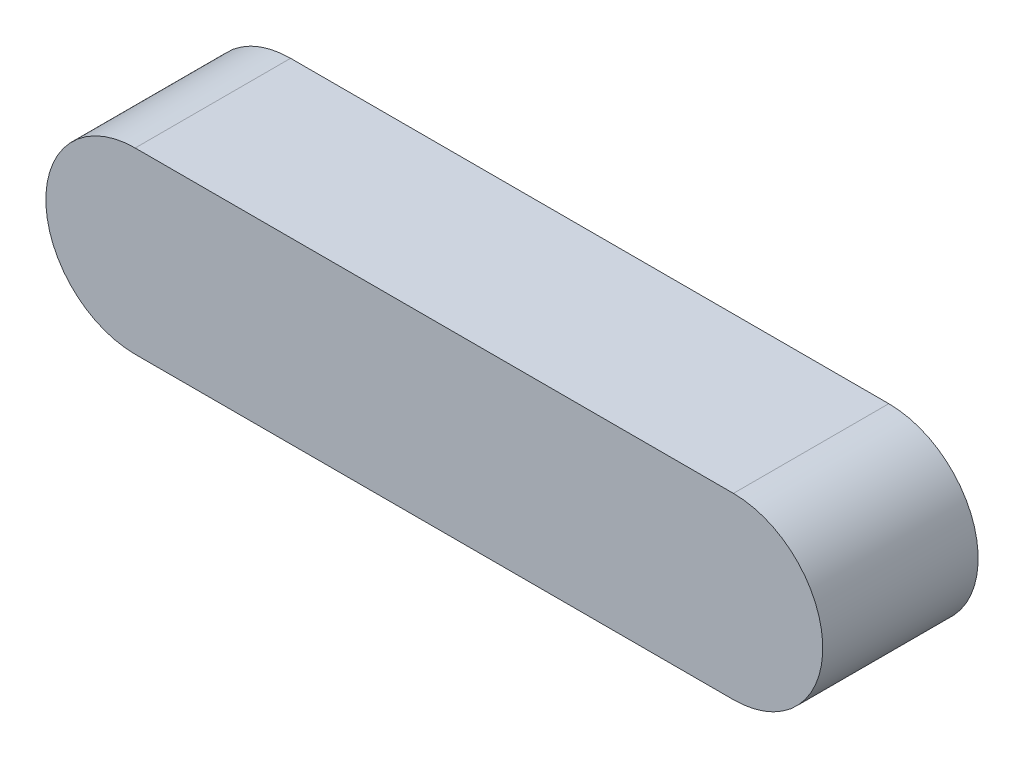
from build123d import *

# Parameters (mm, degrees)
BOSS_EXTRUDE1_DEPTH = 20
SKETCH3_R           = 3
CUT_EXTRUDE1_DEPTH  = 5


with BuildPart() as part:
    # Sketch2 → Boss-Extrude1 (new body)
    with BuildSketch(Plane.XY):
        with BuildLine():
            Line((0, 11.5), (77, 11.5))
            ThreePointArc((77, 11.5), (88.5, 0), (77, -11.5))
            Line((77, -11.5), (0, -11.5))
            ThreePointArc((0, -11.5), (-11.5, 0), (0, 11.5))
        make_face()
    extrude(amount=BOSS_EXTRUDE1_DEPTH)

    # Sketch3 → Cut-Extrude1 (cut)
    with BuildSketch(Plane.XZ.offset(11.5)):
        with Locations((38.5, 10)):
            Circle(SKETCH3_R)
    extrude(amount=-CUT_EXTRUDE1_DEPTH, mode=Mode.SUBTRACT)


solid = part.part
